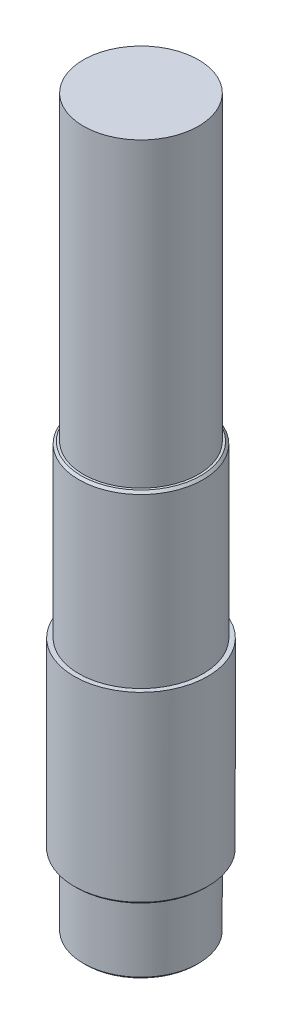
from build123d import *

# Parameters (mm, degrees)
CHAMFER1_SIZE       = 1
CUT_EXTRUDE1_DEPTH  = 6
SKETCH3_R           = 25
BOSS_EXTRUDE1_DEPTH = 100


with BuildPart() as part:
    # Sketch1 → Revolve1 (revolve)
    with BuildSketch(Plane.XY):
        Polygon((0, 87.391304348), (0, -128.608695652), (-25, -128.608695652), (-25, -97.608695652), (-29, -97.608695652), (-29, -17.608695652), (-27, -17.608695652), (-27, 56.391304348), (-25, 56.391304348), (-25, 87.391304348), align=None)
    revolve(axis=Axis((0, 87.391304348, 0), (0, -1, 0)))

    # Chamfer1
    chamfer1_edges = [part.edges().sort_by_distance(p)[0] for p in [
        (27, 56.391304348, 0),
        (25, -128.608695652, 0),
        (29, -97.608695652, 0),
    ]]
    chamfer(chamfer1_edges, length=CHAMFER1_SIZE)

    # Sketch2 → Cut-Extrude1 (cut)
    with BuildSketch(Plane.ZY.offset(27)):
        with BuildLine():
            Line((-8, -9.088294883), (-8, 38.911705117))
            ThreePointArc((-8, 38.911705117), (0, 46.911705117), (8, 38.911705117))
            Line((8, 38.911705117), (8, -9.088294883))
            ThreePointArc((8, -9.088294883), (0, -17.088294883), (-8, -9.088294883))
        make_face()
    extrude(amount=-CUT_EXTRUDE1_DEPTH, mode=Mode.SUBTRACT)

    # Sketch3 → Boss-Extrude1 (add)
    with BuildSketch(Plane(origin=(0, 87.391304348, 0), x_dir=(1, 0, 0), z_dir=(0, 1, 0))):
        Circle(SKETCH3_R)
    extrude(amount=BOSS_EXTRUDE1_DEPTH)


solid = part.part
